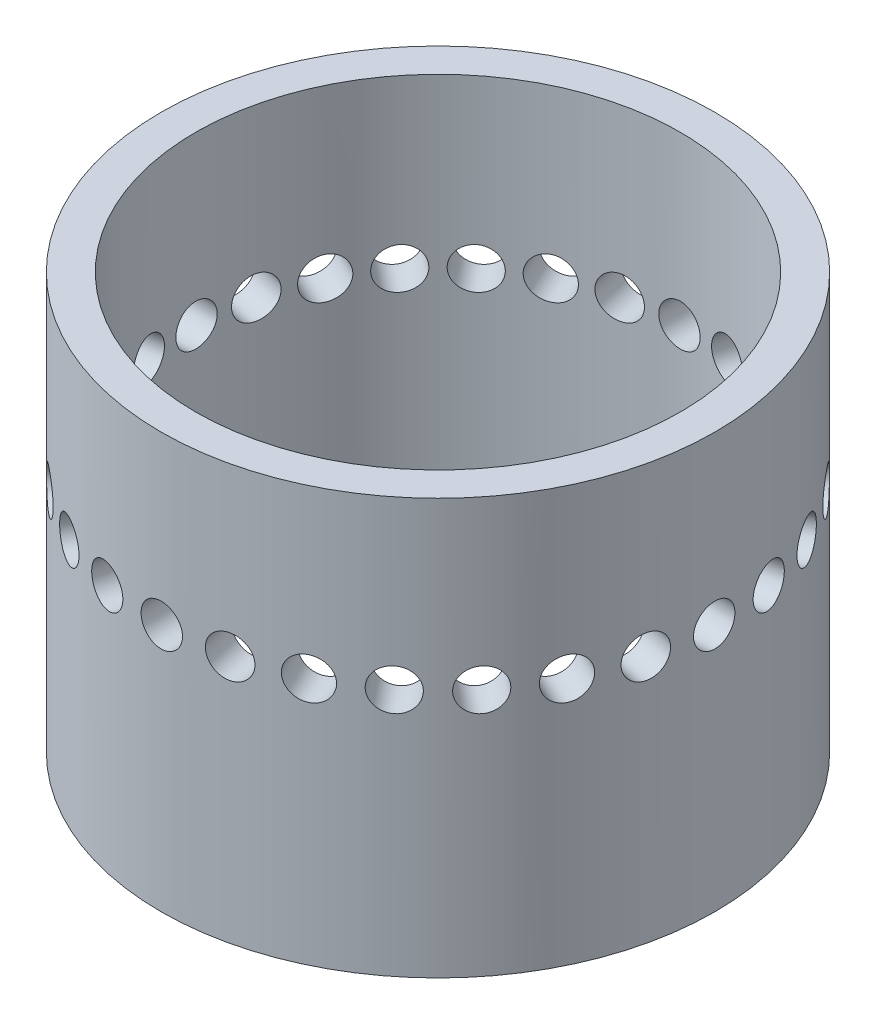
from build123d import *

# Parameters (mm, degrees)
SKETCH1_R           = 25.4
SKETCH1_R_2         = 22.225
BOSS_EXTRUDE1_DEPTH = 38.1
SKETCH3_R           = 1.89865
CUT_EXTRUDE1_DEPTH  = 68.326
CIRPATTERN1_COUNT   = 28


with BuildPart() as part:
    # Sketch1 → Boss-Extrude1 (new body)
    with BuildSketch(Plane(origin=(0, 0, 0), x_dir=(1, 0, 0), z_dir=(0, 1, 0))):
        Circle(SKETCH1_R)
        Circle(SKETCH1_R_2, mode=Mode.SUBTRACT)
    extrude(amount=BOSS_EXTRUDE1_DEPTH)

    # Sketch3 → Cut-Extrude1 (cut)
    with BuildSketch(Plane(origin=(0, 0, 0), x_dir=(0, 0, -1), z_dir=(1, 0, 0))):
        with Locations((0, 22.775333333)):
            Circle(SKETCH3_R)
    cut_extrude1 = extrude(amount=-CUT_EXTRUDE1_DEPTH, mode=Mode.SUBTRACT)

    # CirPattern1: Cut-Extrude1 ×28 about axis
    cirpattern1_axis = Axis((0, 0, 0), (0, 1, 0))
    for i in range(1, CIRPATTERN1_COUNT):
        add(cut_extrude1.rotate(cirpattern1_axis, i * 360 / CIRPATTERN1_COUNT), mode=Mode.SUBTRACT)


solid = part.part
